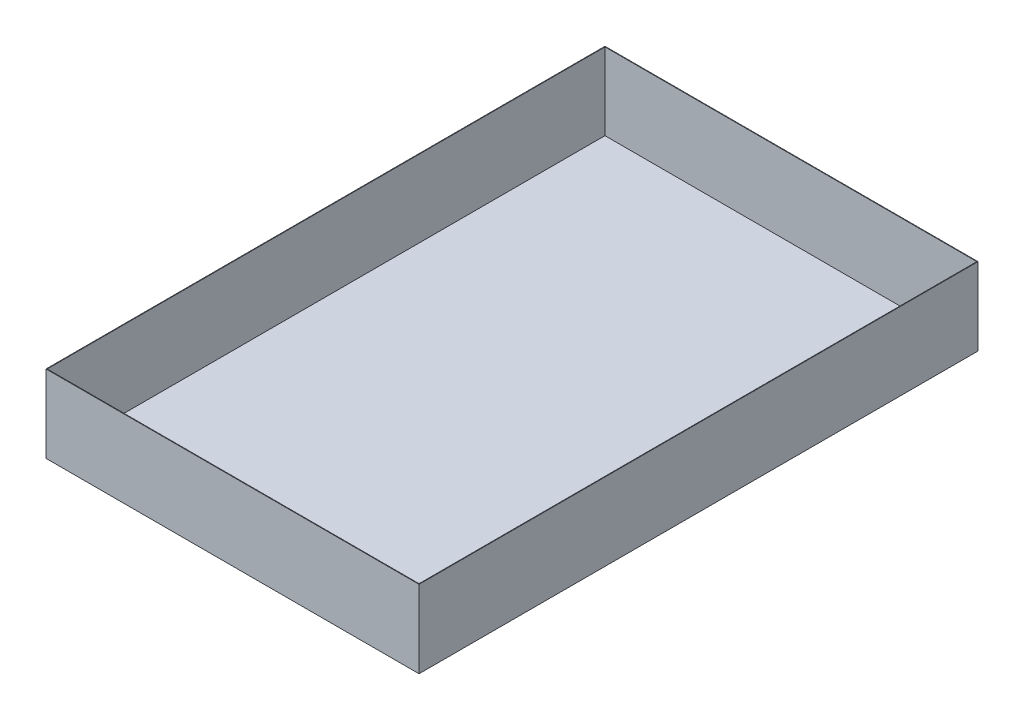
from build123d import *

# Parameters (mm, degrees)
SKETCH1_W           = 481.5
SKETCH1_H           = 721.5
BOSS_EXTRUDE1_DEPTH = 100
SHELL1_T            = -0.75
SKETCH2_R           = 13.5
CUT_EXTRUDE1_DEPTH  = 10


with BuildPart() as part:
    # Sketch1 → Boss-Extrude1 (new body)
    with BuildSketch(Plane(origin=(0, 0, 0), x_dir=(1, 0, 0), z_dir=(0, 1, 0))):
        Rectangle(SKETCH1_W, SKETCH1_H)
    extrude(amount=BOSS_EXTRUDE1_DEPTH)

    # Shell1
    shell1_openings = [part.faces().sort_by_distance(p)[0] for p in [
        (0, 100, 0),
    ]]
    offset(amount=SHELL1_T, openings=shell1_openings, kind=Kind.INTERSECTION)

    # Sketch2 → Cut-Extrude1 (cut)
    with BuildSketch(Plane(origin=(0, 0.75, 0), x_dir=(1, 0, 0), z_dir=(0, 1, 0))):
        with Locations((120.75, -310.75)):
            Circle(SKETCH2_R)
    extrude(amount=-CUT_EXTRUDE1_DEPTH, mode=Mode.SUBTRACT)


solid = part.part
